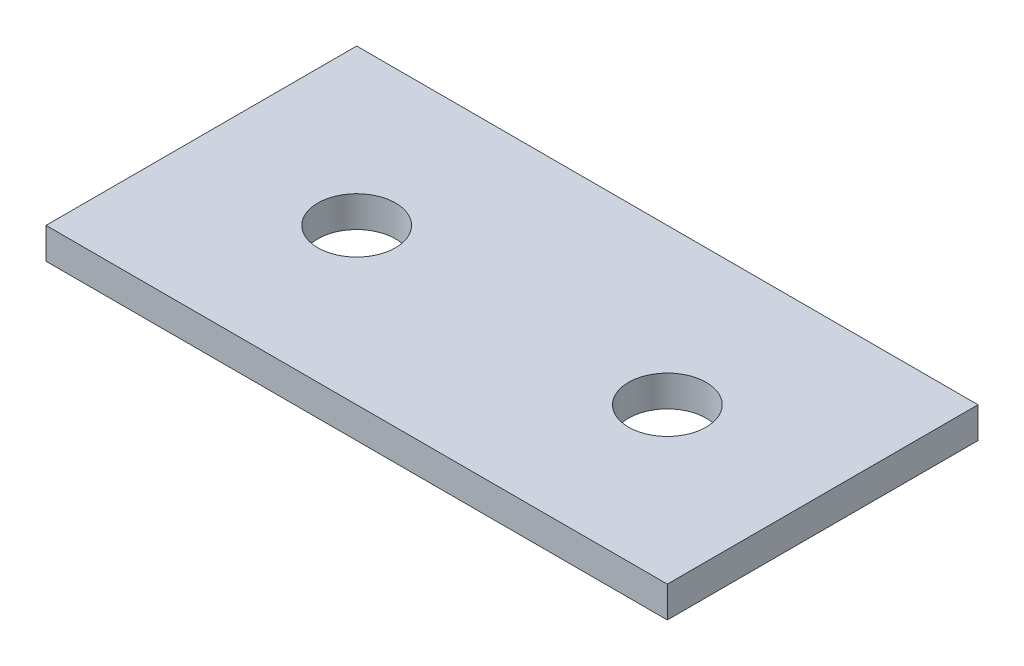
from build123d import *

# Parameters (mm, degrees)
SKETCH1_W           = 50.8
SKETCH1_H           = 25.4
SKETCH1_R           = 3.175
BOSS_EXTRUDE1_DEPTH = 2.54


with BuildPart() as part:
    # Sketch1 → Boss-Extrude1 (new body)
    with BuildSketch(Plane(origin=(0, 0, 0), x_dir=(1, 0, 0), z_dir=(0, 1, 0))):
        with Locations((-25.4, 12.7)):
            Rectangle(SKETCH1_W, SKETCH1_H)
        with Locations((-38.1, 12.7)):
            Circle(SKETCH1_R, mode=Mode.SUBTRACT)
        with Locations((-12.7, 12.7)):
            Circle(SKETCH1_R, mode=Mode.SUBTRACT)
    extrude(amount=BOSS_EXTRUDE1_DEPTH)


solid = part.part
